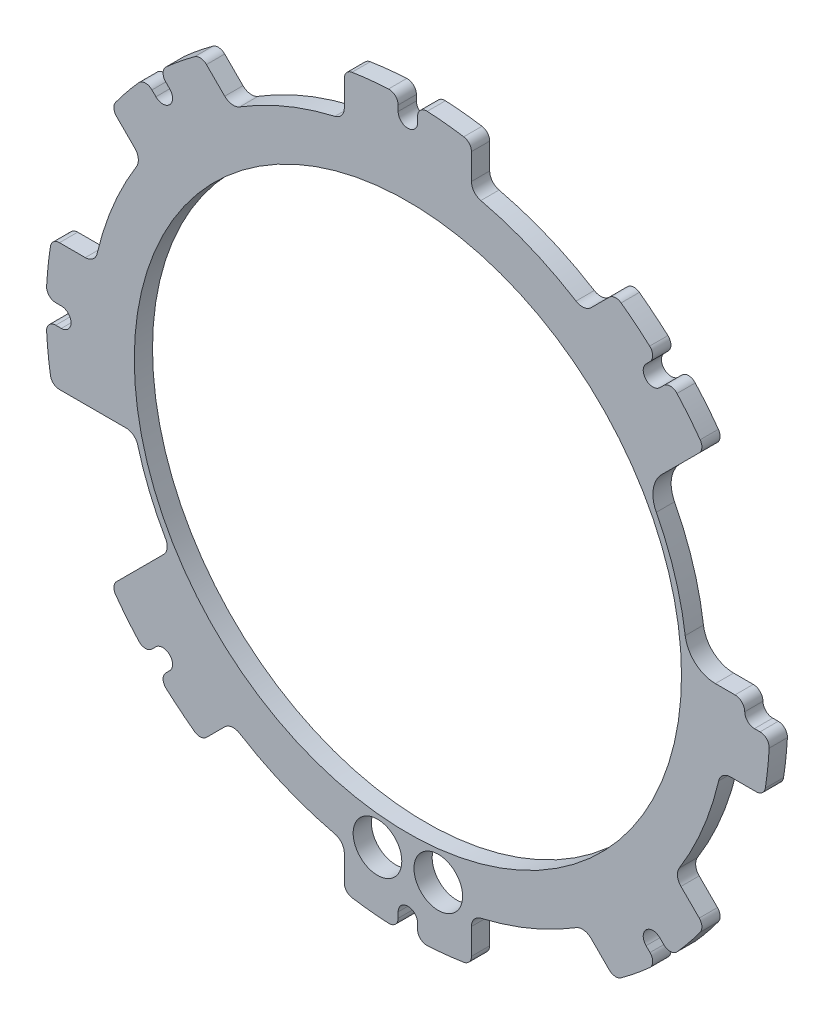
from build123d import *

# Parameters (mm, degrees)
AUFSATZ_LINEAR_AUSTRAGEN1_DEPTH = 3
SKIZZE2_R                       = 45
SCHNITT_LINEAR_AUSTRAGEN1_DEPTH = 4
SKIZZE4_R                       = 4
SCHNITT_LINEAR_AUSTRAGEN3_DEPTH = 4
SCHNITT_LINEAR_AUSTRAGEN4_DEPTH = 4


with BuildPart() as part:
    # Skizze1 → Aufsatz-Linear austragen1 (new body)
    with BuildSketch(Plane.XY):
        with BuildLine():
            Line((10.457142857, 53.057229402), (10.457142857, 57.304184767))
            ThreePointArc((10.457142857, 57.304184767), (10.096764586, 58.279511541), (9.188793103, 58.786189546))
            ThreePointArc((9.188793103, 58.786189546), (6.192468207, 59.176881782), (3.180172414, 59.414951851))
            ThreePointArc((3.180172414, 59.414951851), (2.068074281, 59.005732367), (1.6, 57.917095922))
            Line((1.6, 57.917095922), (1.6, 57))
            ThreePointArc((1.6, 57), (0, 55.4), (-1.6, 57))
            Line((-1.6, 57), (-1.6, 57.917095922))
            ThreePointArc((-1.6, 57.917095922), (-2.068074281, 59.005732367), (-3.180172414, 59.414951851))
            ThreePointArc((-3.180172414, 59.414951851), (-6.192468207, 59.176881782), (-9.188793103, 58.786189546))
            ThreePointArc((-9.188793103, 58.786189546), (-10.096764586, 58.279511541), (-10.457142857, 57.304184767))
            Line((-10.457142857, 57.304184767), (-10.457142857, 53.057229402))
            ThreePointArc((-10.457142857, 53.057229402), (-10.889615232, 51.815111395), (-12, 51.110175112))
            ThreePointArc((-12, 51.110175112), (-16.098279663, 49.970945477), (-20.090880199, 48.503675457))
            ThreePointArc((-20.090880199, 48.503675457), (-23.951591694, 46.717997124), (-27.655070035, 44.625632784))
            ThreePointArc((-27.655070035, 44.625632784), (-28.938695861, 44.33893741), (-30.122810075, 44.911443327))
            Line((-30.122810075, 44.911443327), (-33.125861013, 47.914494265))
            ThreePointArc((-33.125861013, 47.914494265), (-34.070347108, 48.349328522), (-35.070655354, 48.065571182))
            ThreePointArc((-35.070655354, 48.065571182), (-37.465638136, 46.22311066), (-39.763993878, 44.261436837))
            ThreePointArc((-39.763993878, 44.261436837), (-40.261004138, 43.185702834), (-39.822200423, 42.084942123))
            Line((-39.822200423, 42.084942123), (-39.173715678, 41.436457378))
            ThreePointArc((-39.173715678, 41.436457378), (-39.173715678, 39.173715678), (-41.436457378, 39.173715678))
            Line((-41.436457378, 39.173715678), (-42.084942123, 39.822200423))
            ThreePointArc((-42.084942123, 39.822200423), (-43.185702834, 40.261004138), (-44.261436837, 39.763993878))
            ThreePointArc((-44.261436837, 39.763993878), (-46.22311066, 37.465638136), (-48.065571182, 35.070655354))
            ThreePointArc((-48.065571182, 35.070655354), (-48.349328522, 34.070347108), (-47.914494265, 33.125861013))
            Line((-47.914494265, 33.125861013), (-44.911443327, 30.122810075))
            ThreePointArc((-44.911443327, 30.122810075), (-44.33893741, 28.938695861), (-44.625632784, 27.655070035))
            ThreePointArc((-44.625632784, 27.655070035), (-46.717997124, 23.951591694), (-48.503675457, 20.090880199))
            ThreePointArc((-48.503675457, 20.090880199), (-49.970945477, 16.098279663), (-51.110175112, 12))
            ThreePointArc((-51.110175112, 12), (-51.815111395, 10.889615232), (-53.057229402, 10.457142857))
            Line((-53.057229402, 10.457142857), (-57.304184767, 10.457142857))
            ThreePointArc((-57.304184767, 10.457142857), (-58.279511541, 10.096764586), (-58.786189546, 9.188793103))
            ThreePointArc((-58.786189546, 9.188793103), (-59.176881782, 6.192468207), (-59.414951851, 3.180172414))
            ThreePointArc((-59.414951851, 3.180172414), (-59.005732367, 2.068074281), (-57.917095922, 1.6))
            Line((-57.917095922, 1.6), (-57, 1.6))
            ThreePointArc((-57, 1.6), (-55.4, 0), (-57, -1.6))
            Line((-57, -1.6), (-57.917095922, -1.6))
            ThreePointArc((-57.917095922, -1.6), (-59.005732367, -2.068074281), (-59.414951851, -3.180172414))
            ThreePointArc((-59.414951851, -3.180172414), (-59.176881782, -6.192468207), (-58.786189546, -9.188793103))
            ThreePointArc((-58.786189546, -9.188793103), (-58.279511541, -10.096764586), (-57.304184767, -10.457142857))
            Line((-57.304184767, -10.457142857), (-53.057229402, -10.457142857))
            ThreePointArc((-53.057229402, -10.457142857), (-51.815111395, -10.889615232), (-51.110175112, -12))
            ThreePointArc((-51.110175112, -12), (-49.970945477, -16.098279663), (-48.503675457, -20.090880199))
            ThreePointArc((-48.503675457, -20.090880199), (-46.717997124, -23.951591694), (-44.625632784, -27.655070035))
            ThreePointArc((-44.625632784, -27.655070035), (-44.33893741, -28.938695861), (-44.911443327, -30.122810075))
            Line((-44.911443327, -30.122810075), (-47.914494265, -33.125861013))
            ThreePointArc((-47.914494265, -33.125861013), (-48.349328522, -34.070347108), (-48.065571182, -35.070655354))
            ThreePointArc((-48.065571182, -35.070655354), (-46.22311066, -37.465638136), (-44.261436837, -39.763993878))
            ThreePointArc((-44.261436837, -39.763993878), (-43.185702834, -40.261004138), (-42.084942123, -39.822200423))
            Line((-42.084942123, -39.822200423), (-41.436457378, -39.173715678))
            ThreePointArc((-41.436457378, -39.173715678), (-39.173715678, -39.173715678), (-39.173715678, -41.436457378))
            Line((-39.173715678, -41.436457378), (-39.822200423, -42.084942123))
            ThreePointArc((-39.822200423, -42.084942123), (-40.261004138, -43.185702834), (-39.763993878, -44.261436837))
            ThreePointArc((-39.763993878, -44.261436837), (-37.465638136, -46.22311066), (-35.070655354, -48.065571182))
            ThreePointArc((-35.070655354, -48.065571182), (-34.070347108, -48.349328522), (-33.125861013, -47.914494265))
            Line((-33.125861013, -47.914494265), (-30.122810075, -44.911443327))
            ThreePointArc((-30.122810075, -44.911443327), (-28.938695861, -44.33893741), (-27.655070035, -44.625632784))
            ThreePointArc((-27.655070035, -44.625632784), (-23.951591694, -46.717997124), (-20.090880199, -48.503675457))
            ThreePointArc((-20.090880199, -48.503675457), (-16.098279663, -49.970945477), (-12, -51.110175112))
            ThreePointArc((-12, -51.110175112), (-10.889615232, -51.815111395), (-10.457142857, -53.057229402))
            Line((-10.457142857, -53.057229402), (-10.457142857, -57.304184767))
            ThreePointArc((-10.457142857, -57.304184767), (-10.096764586, -58.279511541), (-9.188793103, -58.786189546))
            ThreePointArc((-9.188793103, -58.786189546), (-6.192468207, -59.176881782), (-3.180172414, -59.414951851))
            ThreePointArc((-3.180172414, -59.414951851), (-2.068074281, -59.005732367), (-1.6, -57.917095922))
            Line((-1.6, -57.917095922), (-1.6, -57))
            ThreePointArc((-1.6, -57), (0, -55.4), (1.6, -57))
            Line((1.6, -57), (1.6, -57.917095922))
            ThreePointArc((1.6, -57.917095922), (2.068074281, -59.005732367), (3.180172414, -59.414951851))
            ThreePointArc((3.180172414, -59.414951851), (6.192468207, -59.176881782), (9.188793103, -58.786189546))
            ThreePointArc((9.188793103, -58.786189546), (10.096764586, -58.279511541), (10.457142857, -57.304184767))
            Line((10.457142857, -57.304184767), (10.457142857, -53.057229402))
            ThreePointArc((10.457142857, -53.057229402), (10.889615232, -51.815111395), (12, -51.110175112))
            ThreePointArc((12, -51.110175112), (16.098279663, -49.970945477), (20.090880199, -48.503675457))
            ThreePointArc((20.090880199, -48.503675457), (23.951591694, -46.717997124), (27.655070035, -44.625632784))
            ThreePointArc((27.655070035, -44.625632784), (28.938695861, -44.33893741), (30.122810075, -44.911443327))
            Line((30.122810075, -44.911443327), (33.125861013, -47.914494265))
            ThreePointArc((33.125861013, -47.914494265), (34.070347108, -48.349328522), (35.070655354, -48.065571182))
            ThreePointArc((35.070655354, -48.065571182), (37.465638136, -46.22311066), (39.763993878, -44.261436837))
            ThreePointArc((39.763993878, -44.261436837), (40.261004138, -43.185702834), (39.822200423, -42.084942123))
            Line((39.822200423, -42.084942123), (39.173715678, -41.436457378))
            ThreePointArc((39.173715678, -41.436457378), (39.173715678, -39.173715678), (41.436457378, -39.173715678))
            Line((41.436457378, -39.173715678), (42.084942123, -39.822200423))
            ThreePointArc((42.084942123, -39.822200423), (43.185702834, -40.261004138), (44.261436837, -39.763993878))
            ThreePointArc((44.261436837, -39.763993878), (46.22311066, -37.465638136), (48.065571182, -35.070655354))
            ThreePointArc((48.065571182, -35.070655354), (48.349328522, -34.070347108), (47.914494265, -33.125861013))
            Line((47.914494265, -33.125861013), (44.911443327, -30.122810075))
            ThreePointArc((44.911443327, -30.122810075), (44.33893741, -28.938695861), (44.625632784, -27.655070035))
            ThreePointArc((44.625632784, -27.655070035), (46.717997124, -23.951591694), (48.503675457, -20.090880199))
            ThreePointArc((48.503675457, -20.090880199), (49.970945477, -16.098279663), (51.110175112, -12))
            ThreePointArc((51.110175112, -12), (51.815111395, -10.889615232), (53.057229402, -10.457142857))
            Line((53.057229402, -10.457142857), (57.304184767, -10.457142857))
            ThreePointArc((57.304184767, -10.457142857), (58.279511541, -10.096764586), (58.786189546, -9.188793103))
            ThreePointArc((58.786189546, -9.188793103), (59.176881782, -6.192468207), (59.414951851, -3.180172414))
            ThreePointArc((59.414951851, -3.180172414), (59.005732367, -2.068074281), (57.917095922, -1.6))
            Line((57.917095922, -1.6), (57, -1.6))
            ThreePointArc((57, -1.6), (55.4, 0), (57, 1.6))
            Line((57, 1.6), (57.917095922, 1.6))
            ThreePointArc((57.917095922, 1.6), (59.005732367, 2.068074281), (59.414951851, 3.180172414))
            ThreePointArc((59.414951851, 3.180172414), (59.176881782, 6.192468207), (58.786189546, 9.188793103))
            ThreePointArc((58.786189546, 9.188793103), (58.279511541, 10.096764586), (57.304184767, 10.457142857))
            Line((57.304184767, 10.457142857), (53.057229402, 10.457142857))
            ThreePointArc((53.057229402, 10.457142857), (51.815111395, 10.889615232), (51.110175112, 12))
            ThreePointArc((51.110175112, 12), (49.970945477, 16.098279663), (48.503675457, 20.090880199))
            ThreePointArc((48.503675457, 20.090880199), (46.717997124, 23.951591694), (44.625632784, 27.655070035))
            ThreePointArc((44.625632784, 27.655070035), (44.33893741, 28.938695861), (44.911443327, 30.122810075))
            Line((44.911443327, 30.122810075), (47.914494265, 33.125861013))
            ThreePointArc((47.914494265, 33.125861013), (48.349328522, 34.070347108), (48.065571182, 35.070655354))
            ThreePointArc((48.065571182, 35.070655354), (46.22311066, 37.465638136), (44.261436837, 39.763993878))
            ThreePointArc((44.261436837, 39.763993878), (43.185702834, 40.261004138), (42.084942123, 39.822200423))
            Line((42.084942123, 39.822200423), (41.436457378, 39.173715678))
            ThreePointArc((41.436457378, 39.173715678), (39.173715678, 39.173715678), (39.173715678, 41.436457378))
            Line((39.173715678, 41.436457378), (39.822200423, 42.084942123))
            ThreePointArc((39.822200423, 42.084942123), (40.261004138, 43.185702834), (39.763993878, 44.261436837))
            ThreePointArc((39.763993878, 44.261436837), (37.465638136, 46.22311066), (35.070655354, 48.065571182))
            ThreePointArc((35.070655354, 48.065571182), (34.070347108, 48.349328522), (33.125861013, 47.914494265))
            Line((33.125861013, 47.914494265), (30.122810075, 44.911443327))
            ThreePointArc((30.122810075, 44.911443327), (28.938695861, 44.33893741), (27.655070035, 44.625632784))
            ThreePointArc((27.655070035, 44.625632784), (23.951591694, 46.717997124), (20.090880199, 48.503675457))
            ThreePointArc((20.090880199, 48.503675457), (16.098279663, 49.970945477), (12, 51.110175112))
            ThreePointArc((12, 51.110175112), (10.889615232, 51.815111395), (10.457142857, 53.057229402))
        make_face()
    extrude(amount=AUFSATZ_LINEAR_AUSTRAGEN1_DEPTH)

    # Skizze2 → Schnitt-Linear austragen1 (cut, through all)
    with BuildSketch(Plane.XY.offset(3)):
        Circle(SKIZZE2_R)
    extrude(amount=-SCHNITT_LINEAR_AUSTRAGEN1_DEPTH, mode=Mode.SUBTRACT)

    # Skizze4 → Schnitt-Linear austragen3 (cut, through all)
    with BuildSketch(Plane.XY.offset(3)):
        with Locations((-5, -49.5)):
            Circle(SKIZZE4_R)
        with Locations((5, -49.5)):
            Circle(SKIZZE4_R)
    extrude(amount=-SCHNITT_LINEAR_AUSTRAGEN3_DEPTH, mode=Mode.SUBTRACT)

    # Skizze5 → Schnitt-Linear austragen4 (cut, through all)
    with BuildSketch(Plane.XY.offset(3)):
        with BuildLine():
            Line((-53.057229402, -10.457142857), (-44.911443327, -30.122810075))
            Line((-44.911443327, -30.122810075), (-40.172507484, -25.383874232))
            ThreePointArc((-40.172507484, -25.383874232), (-39.6039267, -24.231436491), (-39.853941003, -22.970924808))
            ThreePointArc((-39.853941003, -22.970924808), (-42.498458496, -17.603437889), (-44.423888642, -11.938095238))
            ThreePointArc((-44.423888642, -11.938095238), (-45.138418192, -10.869992071), (-46.355362061, -10.457142857))
            Line((-46.355362061, -10.457142857), (-53.057229402, -10.457142857))
        make_face()
        with BuildLine():
            Line((44.911443327, 30.122810075), (41.760555398, 26.971922146))
            ThreePointArc((41.760555398, 26.971922146), (40.355233198, 24.20316131), (40.855296235, 21.138703119))
            ThreePointArc((40.855296235, 21.138703119), (43.89591473, 13.753133098), (45.613183306, 5.952941176))
            ThreePointArc((45.613183306, 5.952941176), (47.272296862, 2.842654253), (50.571138014, 1.6))
            Line((50.571138014, 1.6), (53.8, 1.6))
            ThreePointArc((53.8, 1.6), (54.93137085, 1.13137085), (55.4, 0))
            ThreePointArc((55.4, 0), (55.86862915, 1.13137085), (57, 1.6))
            Line((57, 1.6), (57.917095922, 1.6))
            ThreePointArc((57.917095922, 1.6), (59.005732367, 2.068074281), (59.414951851, 3.180172414))
            Line((59.414951851, 3.180172414), (57.309262433, 42.520629181))
            Line((57.309262433, 42.520629181), (44.911443327, 30.122810075))
        make_face()
    extrude(amount=-SCHNITT_LINEAR_AUSTRAGEN4_DEPTH, mode=Mode.SUBTRACT)


solid = part.part
